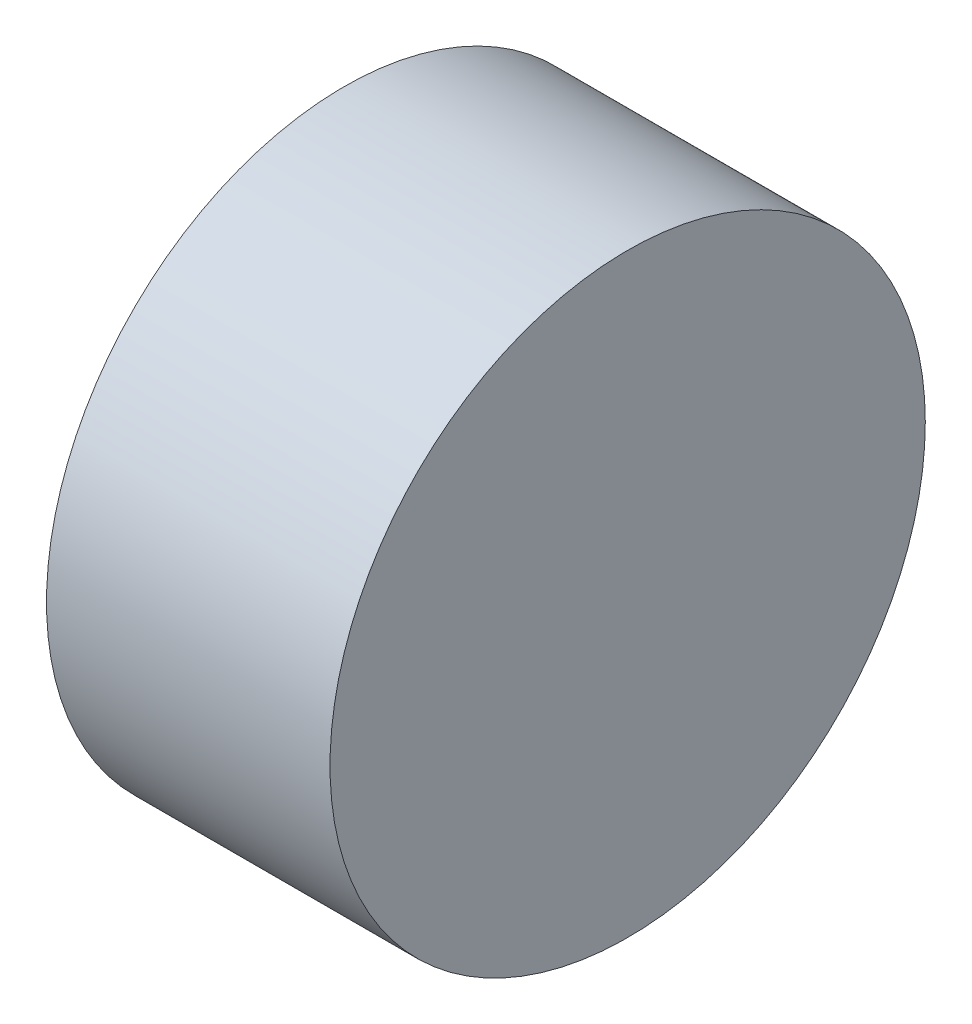
from build123d import *

# Parameters (mm, degrees)
SKETCH1_R           = 64.8
BOSS_EXTRUDE1_DEPTH = 61.72


with BuildPart() as part:
    # Sketch1 → Boss-Extrude1 (new body)
    with BuildSketch(Plane(origin=(0, 0, 0), x_dir=(0, 0, -1), z_dir=(1, 0, 0))):
        Circle(SKETCH1_R)
    extrude(amount=BOSS_EXTRUDE1_DEPTH)


solid = part.part
